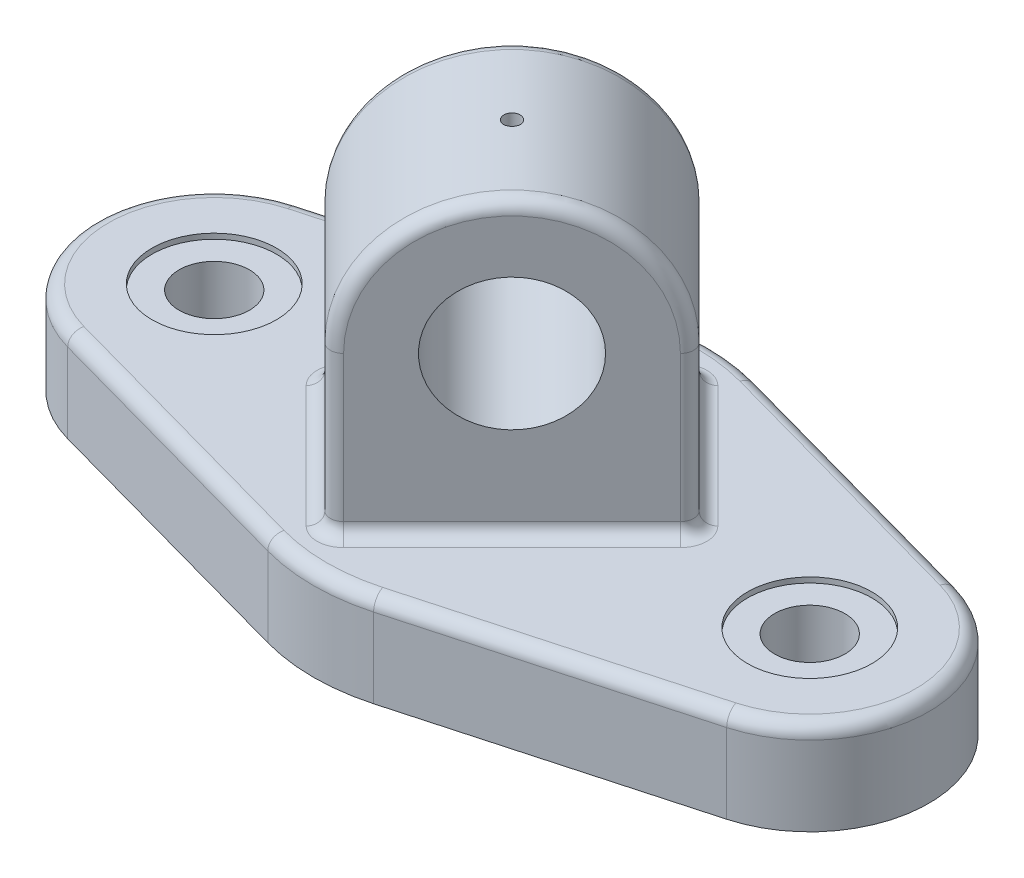
from build123d import *

# Parameters (mm, degrees)
BOSS_EXTRUDE2_DEPTH                = 17.78
SKETCH2_R                          = 6.7437
CUT_EXTRUDE1_DEPTH                 = 91.384393011
SKETCH3_R                          = 11.938
CUT_EXTRUDE2_DEPTH                 = 1.016
BOSS_EXTRUDE3_DEPTH                = 19.05
BOSS_EXTRUDE3_DEPTH_BACK           = 19.05
SKETCH9_R                          = 12.7
CUT_EXTRUDE5_DEPTH                 = 130.70690942
F_1_8_0_125_DIAMETER_HOLE14_REACH  = 117.235
F_1_8_0_125_DIAMETER_HOLE14_BORE_R = 1.5875
FILLET1_R                          = 2.54


with BuildPart() as part:
    # Sketch1 → Boss-Extrude2 (new body)
    with BuildSketch(Plane(origin=(0, 0, 0), x_dir=(1, 0, 0), z_dir=(0, 1, 0))):
        with BuildLine():
            Line((-63.246, 22.032212417), (-10.16, 36.720354029))
            ThreePointArc((-10.16, 36.720354029), (0, 38.1), (10.16, 36.720354029))
            Line((10.16, 36.720354029), (63.246, 22.032212417))
            ThreePointArc((63.246, 22.032212417), (80.01, 0), (63.246, -22.032212417))
            Line((63.246, -22.032212417), (10.16, -36.720354029))
            ThreePointArc((10.16, -36.720354029), (0, -38.1), (-10.16, -36.720354029))
            Line((-10.16, -36.720354029), (-63.246, -22.032212417))
            ThreePointArc((-63.246, -22.032212417), (-80.01, 0), (-63.246, 22.032212417))
        make_face()
    extrude(amount=BOSS_EXTRUDE2_DEPTH)

    # Sketch2 → Cut-Extrude1 (cut, through all)
    with BuildSketch(Plane(origin=(0, 17.78, 0), x_dir=(1, 0, 0), z_dir=(0, 1, 0))):
        with Locations(Location((-57.15, 0, 0), (0, 0, 270))):
            Circle(SKETCH2_R)
    cut_extrude1 = extrude(amount=-CUT_EXTRUDE1_DEPTH, mode=Mode.SUBTRACT)

    # Sketch3 → Cut-Extrude2 (cut)
    with BuildSketch(Plane(origin=(0, 17.78, 0), x_dir=(1, 0, 0), z_dir=(0, 1, 0))):
        with Locations(Location((-57.15, 0, 0), (0, 0, 270))):
            Circle(SKETCH3_R)
    cut_extrude2 = extrude(amount=-CUT_EXTRUDE2_DEPTH, mode=Mode.SUBTRACT)

    # Mirror1: Cut-Extrude1, Cut-Extrude2 across plane
    add(cut_extrude1.mirror(Plane(origin=(0, 0, 0), x_dir=(0, 0, 1), z_dir=(1, 0, 0))), mode=Mode.SUBTRACT)
    add(cut_extrude2.mirror(Plane(origin=(0, 0, 0), x_dir=(0, 0, 1), z_dir=(1, 0, 0))), mode=Mode.SUBTRACT)

    # Sketch8 → Boss-Extrude3 (add, two sides)
    with BuildSketch(Plane(origin=(0, 0, 0), x_dir=(0, -1, 0), z_dir=(0.7071067811865464, 0, 0.7071067811865488))) as boss_extrude3_sk:
        with BuildLine():
            Line((-48.26, -25.4), (-17.78, -25.4))
            Line((-17.78, -25.4), (-17.78, 25.4))
            Line((-17.78, 25.4), (-48.26, 25.4))
            ThreePointArc((-48.26, 25.4), (-73.66, 0), (-48.26, -25.4))
        make_face()
    extrude(amount=BOSS_EXTRUDE3_DEPTH)
    extrude(boss_extrude3_sk.sketch, amount=-BOSS_EXTRUDE3_DEPTH_BACK)

    # Sketch9 → Cut-Extrude5 (cut, through all)
    with BuildSketch(Plane(origin=(13.470384182, 0, 13.470384182), x_dir=(0.7071067811865487, 0, -0.7071067811865465), z_dir=(0.7071067811865465, 0, 0.7071067811865487))):
        with Locations((0, 48.26)):
            Circle(SKETCH9_R)
    extrude(amount=-CUT_EXTRUDE5_DEPTH, mode=Mode.SUBTRACT)

    # 1_8 _0.125_ Diameter Hole14 bore → 1_8 _0.125_ Diameter Hole14 (cut, up to next)
    with BuildSketch(Plane(origin=(0, 73.66, 0), x_dir=(1, 0, 0), z_dir=(0, 1, 0)), mode=Mode.PRIVATE) as f_1_8_0_125_diameter_hole14_sk1:
        Circle(F_1_8_0_125_DIAMETER_HOLE14_BORE_R)
    f_1_8_0_125_diameter_hole14_tool1 = extrude(f_1_8_0_125_diameter_hole14_sk1.sketch, amount=-F_1_8_0_125_DIAMETER_HOLE14_REACH, mode=Mode.PRIVATE) & part.part
    add(f_1_8_0_125_diameter_hole14_tool1.solids().sort_by_distance((0, 73.66, 0))[0], mode=Mode.SUBTRACT)

    # Fillet1
    fillet1_edges = [part.edges().sort_by_distance(p)[0] for p in [
        (0, 17.78, 38.1),
        (36.703, 17.78, 29.376283223),
        (80.01, 17.78, 0),
        (36.703, 17.78, -29.376283223),
        (0, 17.78, -38.1),
        (-36.703, 17.78, -29.376283223),
        (-80.01, 17.78, 0),
        (4.490128061, 33.02, -31.430896424),
        (17.960512242, 17.78, -17.960512242),
        (-13.470384182, 17.78, -13.470384182),
        (-17.960512242, 17.78, 17.960512242),
        (-31.430896424, 33.02, 4.490128061),
        (-13.470384182, 73.66, -13.470384182),
        (31.430896424, 33.02, -4.490128061),
        (13.470384182, 73.66, 13.470384182),
        (-4.490128061, 33.02, 31.430896424),
        (13.470384182, 17.78, 13.470384182),
        (-36.703, 17.78, 29.376283223),
    ]]
    fillet(fillet1_edges, radius=FILLET1_R)


solid = part.part
